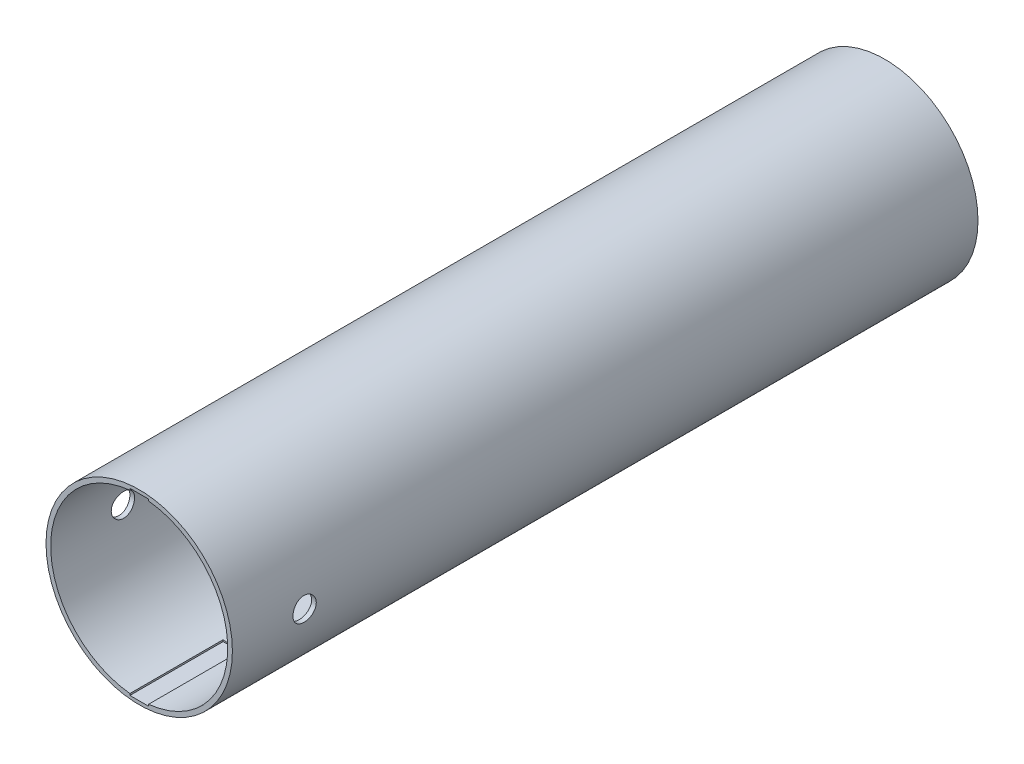
from build123d import *

# Parameters (mm, degrees)
SKETCH1_R           = 10
BOSS_EXTRUDE1_DEPTH = 80
SHELL1_T            = -0.5
SKETCH4_R           = 1.25
CUT_EXTRUDE3_DEPTH  = 84.066238629
SKETCH8_W           = 2
SKETCH8_H           = 0.25
CUT_EXTRUDE5_DEPTH  = 10


with BuildPart() as part:
    # Sketch1 → Boss-Extrude1 (new body)
    with BuildSketch(Plane.XY):
        Circle(SKETCH1_R)
    extrude(amount=BOSS_EXTRUDE1_DEPTH)

    # Shell1
    shell1_openings = [part.faces().sort_by_distance(p)[0] for p in [
        (0, 0, 80),
    ]]
    offset(amount=SHELL1_T, openings=shell1_openings, kind=Kind.INTERSECTION)

    # Sketch4 → Cut-Extrude3 (cut, through all)
    with BuildSketch(Plane(origin=(10, 0, 0), x_dir=(0, 0, -1), z_dir=(1, 0, 0))):
        with Locations((-72.25, 0)):
            Circle(SKETCH4_R)
    extrude(amount=-CUT_EXTRUDE3_DEPTH, mode=Mode.SUBTRACT)

    # Sketch8 → Cut-Extrude5 (cut)
    with BuildSketch(Plane.XY.offset(80)):
        with Locations((0, -9.5)):
            Rectangle(SKETCH8_W, SKETCH8_H)
        with Locations((0, 9.5)):
            Rectangle(SKETCH8_W, SKETCH8_H)
    extrude(amount=-CUT_EXTRUDE5_DEPTH, mode=Mode.SUBTRACT)


solid = part.part
